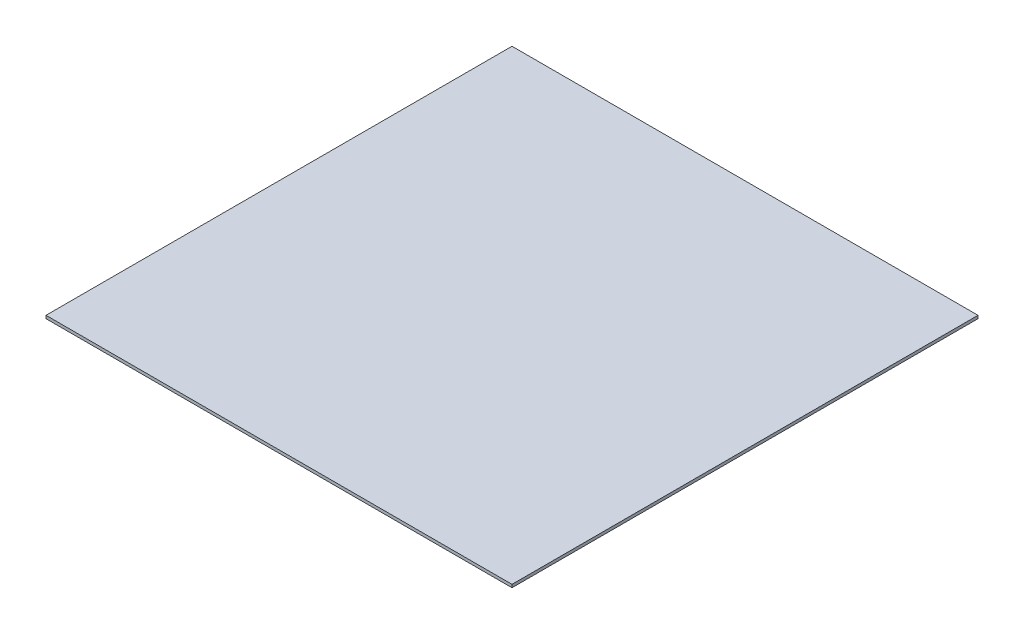
from build123d import *

# Parameters (mm, degrees)
SKETCH1_W           = 40
SKETCH1_H           = 40
BOSS_EXTRUDE1_DEPTH = 0.254


with BuildPart() as part:
    # Sketch1 → Boss-Extrude1 (new body)
    with BuildSketch(Plane(origin=(0, 0, 0), x_dir=(1, 0, 0), z_dir=(0, 1, 0))):
        with Locations((-26.354036253, 8.86515078)):
            Rectangle(SKETCH1_W, SKETCH1_H)
    extrude(amount=BOSS_EXTRUDE1_DEPTH)


solid = part.part
